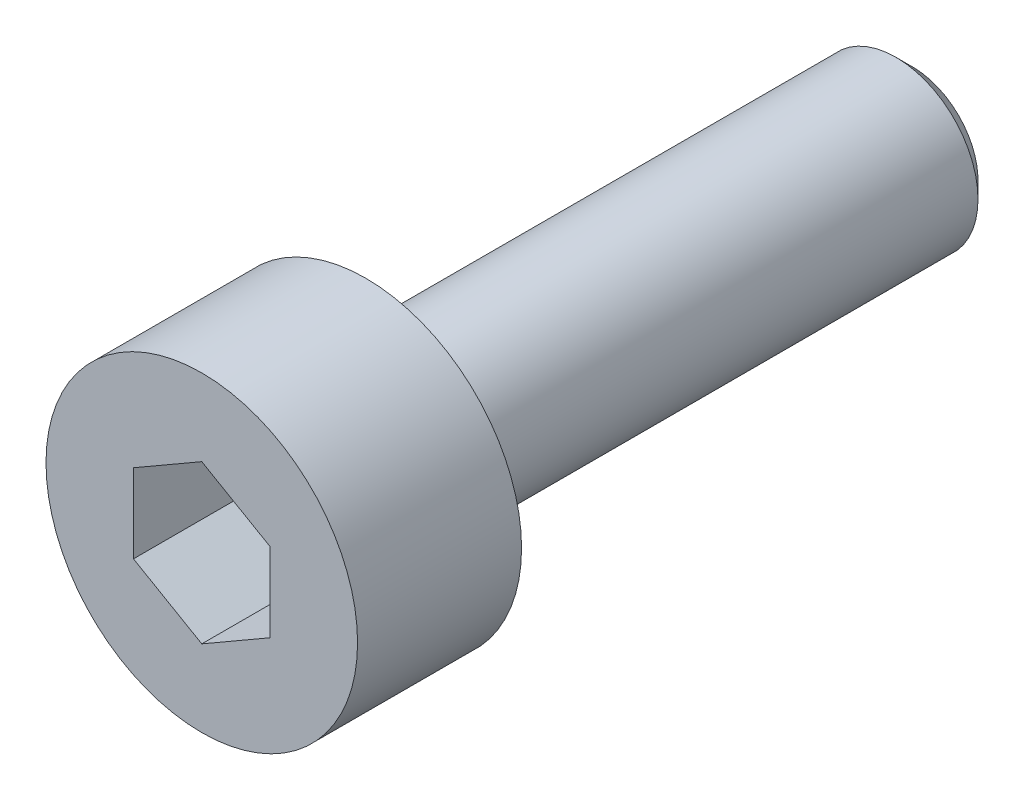
from build123d import *

# Parameters (mm, degrees)
SKETCH1_R           = 2.85
BOSS_EXTRUDE1_DEPTH = 3
SKETCH2_R           = 1.5
BOSS_EXTRUDE2_DEPTH = 10
CHAMFER1_SIZE       = 0.3
CUT_EXTRUDE1_DEPTH  = 2


with BuildPart() as part:
    # Sketch1 → Boss-Extrude1 (new body)
    with BuildSketch(Plane.XY):
        Circle(SKETCH1_R)
    extrude(amount=BOSS_EXTRUDE1_DEPTH)

    # Sketch2 → Boss-Extrude2 (add)
    with BuildSketch(Plane(origin=(0, 0, 0), x_dir=(-1, 0, 0), z_dir=(0, 0, -1))):
        Circle(SKETCH2_R)
    extrude(amount=BOSS_EXTRUDE2_DEPTH)

    # Chamfer1
    chamfer1_edges = [part.edges().sort_by_distance(p)[0] for p in [
        (1.5, 0, -10),
    ]]
    chamfer(chamfer1_edges, length=CHAMFER1_SIZE)

    # Sketch3 → Cut-Extrude1 (cut)
    with BuildSketch(Plane.XY.offset(3)):
        Polygon((0, 1.443375673), (-1.25, 0.721687836), (-1.25, -0.721687836), (0, -1.443375673), (1.25, -0.721687836), (1.25, 0.721687836), align=None)
    extrude(amount=-CUT_EXTRUDE1_DEPTH, mode=Mode.SUBTRACT)


solid = part.part
